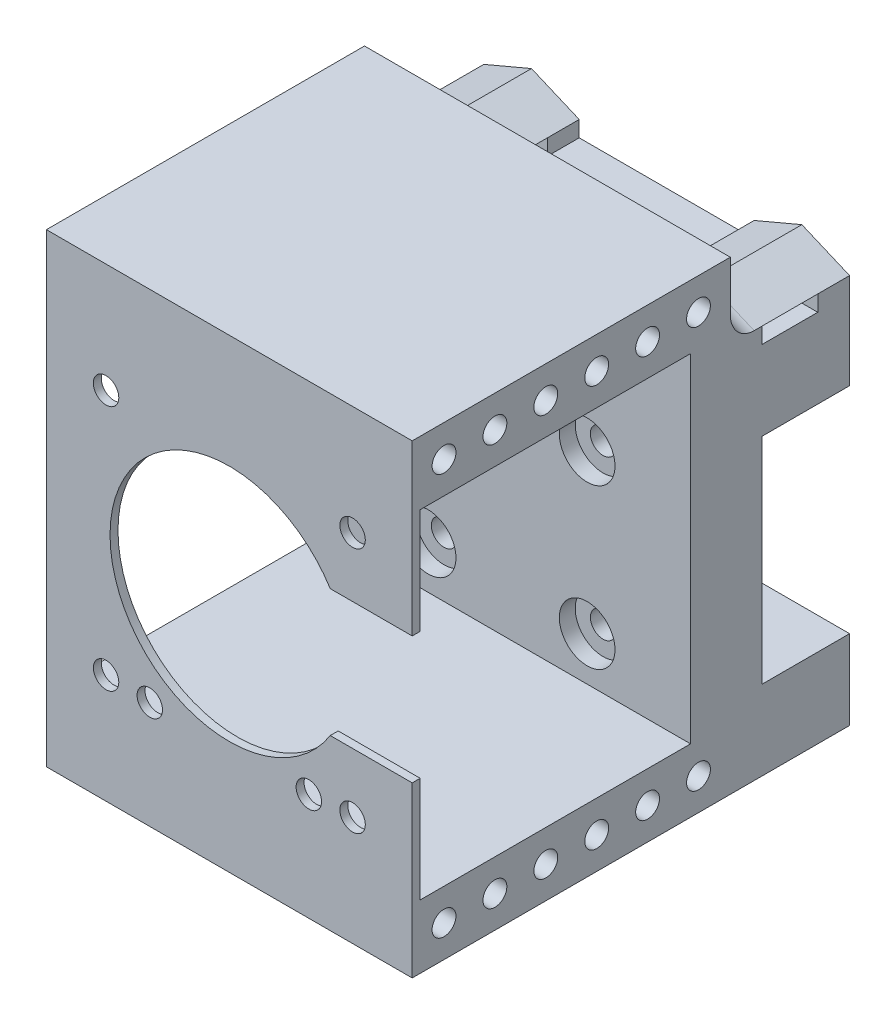
from build123d import *

# Parameters (mm, degrees)
SKETCH1_W               = 46
SKETCH1_H               = 47
BOSS_EXTRUDE1_DEPTH     = 9
SKETCH3_W               = 46
SKETCH3_H               = 10
BOSS_EXTRUDE2_DEPTH     = 11
BOSS_EXTRUDE5_DEPTH     = 15
SKETCH8_W               = 7
SKETCH8_H               = 2
CUT_EXTRUDE3_DEPTH      = 24
CUT_EXTRUDE3_DEPTH_BACK = 24
SKETCH11_W              = 46
SKETCH11_H              = 8
BOSS_EXTRUDE6_DEPTH     = 34
SKETCH12_W              = 46
SKETCH12_H              = 58.5
BOSS_EXTRUDE7_DEPTH     = 1
CUT_EXTRUDE6_REACH      = 57
SKETCH13_R              = 15
SKETCH13_R_2            = 1.6
SKETCH14_W              = 46
SKETCH14_H              = 5
BOSS_EXTRUDE8_DEPTH     = 11.5
SKETCH15_W              = 16
SKETCH15_H              = 15.996045694
CUT_EXTRUDE7_DEPTH      = 3
SKETCH2_R               = 1.6
CUT_EXTRUDE1_DEPTH      = 36
CUT_EXTRUDE1_DEPTH_BACK = 21
SKETCH9_R               = 3.5
CUT_EXTRUDE4_DEPTH      = 2
FILLET1_R               = 3
SKETCH17_R              = 1.5
CUT_EXTRUDE8_DEPTH      = 47
SKETCH20_R              = 1.5
CUT_EXTRUDE10_DEPTH     = 10


with BuildPart() as part:
    # Sketch1 → Boss-Extrude1 (new body)
    with BuildSketch(Plane.XY):
        Rectangle(SKETCH1_W, SKETCH1_H)
    extrude(amount=BOSS_EXTRUDE1_DEPTH)

    # Sketch3 → Boss-Extrude2 (add)
    with BuildSketch(Plane.XY):
        with Locations((0, 18.5)):
            Rectangle(SKETCH3_W, SKETCH3_H)
        with Locations((0, -18.5)):
            Rectangle(SKETCH3_W, SKETCH3_H)
    extrude(amount=-BOSS_EXTRUDE2_DEPTH)

    # Sketch7 → Boss-Extrude5 (add)
    with BuildSketch(Plane(origin=(0, 0, -11), x_dir=(-1, 0, 0), z_dir=(0, 0, -1))):
        Polygon((-23, 23.5), (-11, 23.5), (-11, 25.5), (-17, 28.044850705), (-23, 25.5), align=None)
        Polygon((17, 28.044850705), (11, 25.5), (11, 23.5), (23, 23.5), (23, 25.5), align=None)
    extrude(amount=-BOSS_EXTRUDE5_DEPTH)

    # Sketch8 → Cut-Extrude3 (cut, two sides)
    with BuildSketch(Plane(origin=(0, 0, 0), x_dir=(0, 0, -1), z_dir=(1, 0, 0))) as cut_extrude3_sk:
        with Locations((3.5, 24.5)):
            Rectangle(SKETCH8_W, SKETCH8_H)
    extrude(amount=CUT_EXTRUDE3_DEPTH, mode=Mode.SUBTRACT)
    extrude(cut_extrude3_sk.sketch, amount=-CUT_EXTRUDE3_DEPTH_BACK, mode=Mode.SUBTRACT)

    # Sketch11 → Boss-Extrude6 (add)
    with BuildSketch(Plane.XY.offset(9)):
        with Locations((0, -19.5)):
            Rectangle(SKETCH11_W, SKETCH11_H)
        with Locations((0, 31)):
            Rectangle(SKETCH11_W, SKETCH11_H)
    extrude(amount=BOSS_EXTRUDE6_DEPTH)

    # Sketch12 → Boss-Extrude7 (add)
    with BuildSketch(Plane.XY.offset(43)):
        with Locations((0, 5.75)):
            Rectangle(SKETCH12_W, SKETCH12_H)
    extrude(amount=BOSS_EXTRUDE7_DEPTH)

    # Sketch13 → Cut-Extrude6 (cut, up to next)
    with BuildSketch(Plane.XY.offset(44), mode=Mode.PRIVATE) as cut_extrude6_sk1:
        with Locations((0, 5.75)):
            Circle(SKETCH13_R)
    cut_extrude6_tool1 = extrude(cut_extrude6_sk1.sketch, amount=-CUT_EXTRUDE6_REACH, mode=Mode.PRIVATE) & part.part
    add(cut_extrude6_tool1.solids().sort_by_distance((0, 5.75, 44))[0], mode=Mode.SUBTRACT)
    # Sketch13 → Cut-Extrude6 (cut, up to next)
    with BuildSketch(Plane.XY.offset(44), mode=Mode.PRIVATE) as cut_extrude6_sk2:
        with Locations((-15.5, 21.25)):
            Circle(SKETCH13_R_2)
    cut_extrude6_tool2 = extrude(cut_extrude6_sk2.sketch, amount=-CUT_EXTRUDE6_REACH, mode=Mode.PRIVATE) & part.part
    add(cut_extrude6_tool2.solids().sort_by_distance((-15.5, 21.25, 44))[0], mode=Mode.SUBTRACT)
    # Sketch13 → Cut-Extrude6 (cut, up to next)
    with BuildSketch(Plane.XY.offset(44), mode=Mode.PRIVATE) as cut_extrude6_sk3:
        with Locations((15.5, 21.25)):
            Circle(SKETCH13_R_2)
    cut_extrude6_tool3 = extrude(cut_extrude6_sk3.sketch, amount=-CUT_EXTRUDE6_REACH, mode=Mode.PRIVATE) & part.part
    add(cut_extrude6_tool3.solids().sort_by_distance((15.5, 21.25, 44))[0], mode=Mode.SUBTRACT)
    # Sketch13 → Cut-Extrude6 (cut, up to next)
    with BuildSketch(Plane.XY.offset(44), mode=Mode.PRIVATE) as cut_extrude6_sk4:
        with Locations((15.5, -9.75)):
            Circle(SKETCH13_R_2)
    cut_extrude6_tool4 = extrude(cut_extrude6_sk4.sketch, amount=-CUT_EXTRUDE6_REACH, mode=Mode.PRIVATE) & part.part
    add(cut_extrude6_tool4.solids().sort_by_distance((15.5, -9.75, 44))[0], mode=Mode.SUBTRACT)
    # Sketch13 → Cut-Extrude6 (cut, up to next)
    with BuildSketch(Plane.XY.offset(44), mode=Mode.PRIVATE) as cut_extrude6_sk5:
        with Locations((-15.5, -9.75)):
            Circle(SKETCH13_R_2)
    cut_extrude6_tool5 = extrude(cut_extrude6_sk5.sketch, amount=-CUT_EXTRUDE6_REACH, mode=Mode.PRIVATE) & part.part
    add(cut_extrude6_tool5.solids().sort_by_distance((-15.5, -9.75, 44))[0], mode=Mode.SUBTRACT)

    # Sketch14 → Boss-Extrude8 (add)
    with BuildSketch(Plane(origin=(0, 23.5, 0), x_dir=(1, 0, 0), z_dir=(0, 1, 0))):
        with Locations((0, -6.5)):
            Rectangle(SKETCH14_W, SKETCH14_H)
    extrude(amount=BOSS_EXTRUDE8_DEPTH)

    # Sketch15 → Cut-Extrude7 (cut)
    with BuildSketch(Plane.XY.offset(44)):
        with Locations((15, 5.75)):
            Rectangle(SKETCH15_W, SKETCH15_H)
    extrude(amount=-CUT_EXTRUDE7_DEPTH, mode=Mode.SUBTRACT)

    # Sketch2 → Cut-Extrude1 (cut, two sides)
    with BuildSketch(Plane.XY.offset(9)) as cut_extrude1_sk:
        with Locations((-10, 10)):
            Circle(SKETCH2_R)
        with Locations((10, 10)):
            Circle(SKETCH2_R)
        with Locations((-10, -10)):
            Circle(SKETCH2_R)
        with Locations((10, -10)):
            Circle(SKETCH2_R)
    extrude(amount=CUT_EXTRUDE1_DEPTH, mode=Mode.SUBTRACT)
    extrude(cut_extrude1_sk.sketch, amount=-CUT_EXTRUDE1_DEPTH_BACK, mode=Mode.SUBTRACT)

    # Sketch9 → Cut-Extrude4 (cut)
    with BuildSketch(Plane.XY.offset(9)):
        with Locations((-10, 10)):
            Circle(SKETCH9_R)
        with Locations((10, 10)):
            Circle(SKETCH9_R)
        with Locations((10, -10)):
            Circle(SKETCH9_R)
        with Locations((-10, -10)):
            Circle(SKETCH9_R)
    extrude(amount=-CUT_EXTRUDE4_DEPTH, mode=Mode.SUBTRACT)

    # Fillet1
    fillet1_edges = [part.edges().sort_by_distance(p)[0] for p in [
        (20, 26.772425352, 4),
        (14, 26.772425352, 4),
        (11, 24.5, 4),
        (-20, 26.772425352, 4),
        (-11, 24.5, 4),
        (-14, 26.772425352, 4),
        (0, 23.5, 4),
    ]]
    fillet(fillet1_edges, radius=FILLET1_R)

    # Sketch17 → Cut-Extrude8 (cut, through all)
    with BuildSketch(Plane.ZY.offset(23)):
        with Locations((40, -19.5)):
            Circle(SKETCH17_R)
        with Locations((33.6, -19.5)):
            Circle(SKETCH17_R)
        with Locations((27.2, -19.5)):
            Circle(SKETCH17_R)
        with Locations((20.8, -19.5)):
            Circle(SKETCH17_R)
        with Locations((14.4, -19.5)):
            Circle(SKETCH17_R)
        with Locations((8, -19.5)):
            Circle(SKETCH17_R)
        with Locations((33.6, 31)):
            Circle(SKETCH17_R)
        with Locations((27.2, 31)):
            Circle(SKETCH17_R)
        with Locations((20.8, 31)):
            Circle(SKETCH17_R)
        with Locations((14.4, 31)):
            Circle(SKETCH17_R)
        with Locations((8, 31)):
            Circle(SKETCH17_R)
        with Locations((40, 31)):
            Circle(SKETCH17_R)
    extrude(amount=-CUT_EXTRUDE8_DEPTH, mode=Mode.SUBTRACT)

    # Sketch20 → Cut-Extrude10 (cut)
    with BuildSketch(Plane(origin=(0, 0, -11), x_dir=(-1, 0, 0), z_dir=(0, 0, -1))):
        with Locations((-19, -18.5)):
            Circle(SKETCH20_R)
        with Locations((-12.666666667, -18.5)):
            Circle(SKETCH20_R)
        with Locations((-6.333333333, -18.5)):
            Circle(SKETCH20_R)
        with Locations((0, -18.5)):
            Circle(SKETCH20_R)
        with Locations((6.333333333, -18.5)):
            Circle(SKETCH20_R)
        with Locations((12.666666667, -18.5)):
            Circle(SKETCH20_R)
        with Locations((19, -18.5)):
            Circle(SKETCH20_R)
        with Locations((-19, 18.5)):
            Circle(SKETCH20_R)
        with Locations((-12.666666667, 18.5)):
            Circle(SKETCH20_R)
        with Locations((-6.333333333, 18.5)):
            Circle(SKETCH20_R)
        with Locations((0, 18.5)):
            Circle(SKETCH20_R)
        with Locations((6.333333333, 18.5)):
            Circle(SKETCH20_R)
        with Locations((12.666666667, 18.5)):
            Circle(SKETCH20_R)
        with Locations((19, 18.5)):
            Circle(SKETCH20_R)
    extrude(amount=-CUT_EXTRUDE10_DEPTH, mode=Mode.SUBTRACT)


solid = part.part
